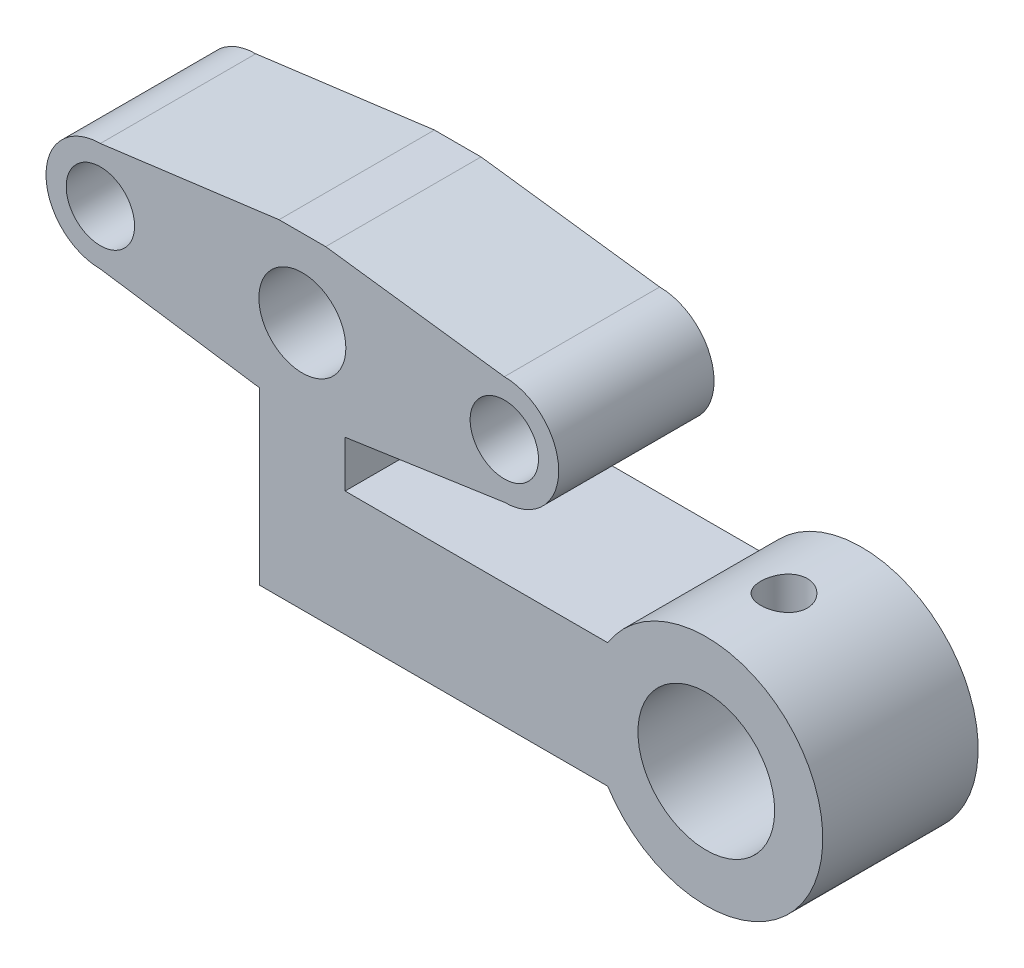
from build123d import *

# Parameters (mm, degrees)
ESQUISSE1_R             = 2.8
ESQUISSE1_W             = 2.75
ESQUISSE1_H             = 8
BOSS_EXTRU_1_DEPTH      = 10
ENL_V_MAT_EXTRU_1_REACH = 17
ESQUISSE2_R             = 1.5
ESQUISSE4_R             = 2.2
ENL_V_MAT_EXTRU_2_DEPTH = 9


with BuildPart() as part:
    # Esquisse1 → Boss.-Extru.1 (new body)
    with BuildSketch(Plane.XY):
        with BuildLine():
            Line((1.5, 5), (-1.5, 5))
            Line((-1.5, 5), (-13, 3.5))
            ThreePointArc((-13, 3.5), (-16.5, 0), (-13, -3.5))
            Line((-13, -3.5), (-2.75, -5))
            Line((-2.75, -5), (2.75, -5))
            Line((2.75, -5), (13, -3.5))
            ThreePointArc((13, -3.5), (16.5, 0), (13, 3.5))
            Line((13, 3.5), (1.5, 5))
        make_face()
        Circle(ESQUISSE1_R, mode=Mode.SUBTRACT)
        Polygon((2.75, -5), (-2.75, -5), (-2.75, -16), (0, -16), (0, -8), (2.75, -8), align=None)
        with Locations((1.375, -12)):
            Rectangle(ESQUISSE1_W, ESQUISSE1_H)
        with BuildLine():
            Line((19.65571123, -8), (2.75, -8))
            Line((2.75, -8), (2.75, -16))
            Line((2.75, -16), (19.65571123, -16))
            ThreePointArc((19.65571123, -16), (18.5, -12), (19.65571123, -8))
        make_face()
        with BuildLine():
            ThreePointArc((33.5, -12), (28.081806214, -4.794718403), (19.65571123, -8))
            Line((19.65571123, -8), (21.6, -8))
            Line((21.6, -8), (21.6, -12))
            Line((21.6, -12), (21.6, -16))
            Line((21.6, -16), (19.65571123, -16))
            ThreePointArc((19.65571123, -16), (28.081806214, -19.205281597), (33.5, -12))
        make_face()
        with BuildLine():
            ThreePointArc((30.4, -12), (26, -16.4), (21.6, -12))
            ThreePointArc((21.6, -12), (26, -7.6), (30.4, -12))
        make_face(mode=Mode.SUBTRACT)
        with BuildLine():
            Line((21.6, -8), (19.65571123, -8))
            ThreePointArc((19.65571123, -8), (18.5, -12), (19.65571123, -16))
            Line((19.65571123, -16), (21.6, -16))
            Line((21.6, -16), (21.6, -12))
            Line((21.6, -12), (21.6, -8))
        make_face()
    extrude(amount=BOSS_EXTRU_1_DEPTH)

    # Esquisse2 → Enlèv. mat.-Extru.1 (cut, up to next)
    with BuildSketch(Plane(origin=(0, -4.5, 0), x_dir=(1, 0, 0), z_dir=(0, 1, 0)), mode=Mode.PRIVATE) as enl_v_mat_extru_1_sk1:
        with Locations((26, -5)):
            Circle(ESQUISSE2_R)
    enl_v_mat_extru_1_tool1 = extrude(enl_v_mat_extru_1_sk1.sketch, amount=-ENL_V_MAT_EXTRU_1_REACH, mode=Mode.PRIVATE) & part.part
    add(enl_v_mat_extru_1_tool1.solids().sort_by_distance((26, -4.5, 5))[0], mode=Mode.SUBTRACT)

    # Esquisse4 → Enlèv. mat.-Extru.2 (cut)
    with BuildSketch(Plane.XY.offset(10)):
        with Locations((-13, 0)):
            Circle(ESQUISSE4_R)
        with Locations((13, 0)):
            Circle(ESQUISSE4_R)
    extrude(amount=-ENL_V_MAT_EXTRU_2_DEPTH, mode=Mode.SUBTRACT)


solid = part.part
